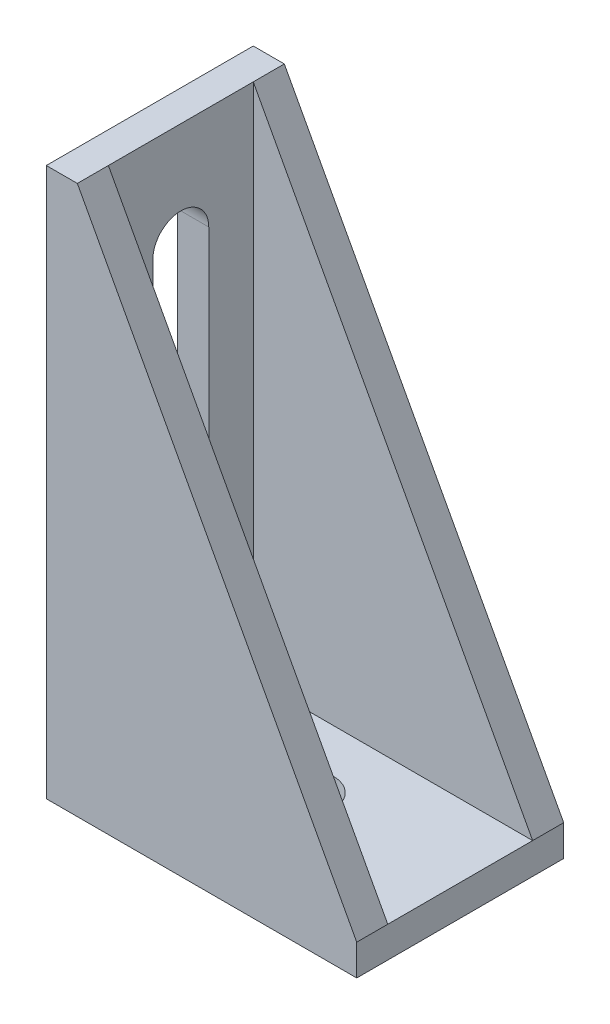
from build123d import *

# Parameters (mm, degrees)
SKETCH1_W           = 30
SKETCH1_H           = 20
SKETCH1_R           = 2.75
BOSS_EXTRUDE1_DEPTH = 3
SKETCH2_W           = 3
SKETCH2_H           = 20
BOSS_EXTRUDE2_DEPTH = 50
RIB1_REACH          = 60.6
SKETCH3_WALL_W      = 176.024973172
SKETCH3_WALL_H      = 3
CUT_EXTRUDE1_DEPTH  = 61.3158354


with BuildPart() as part:
    # Sketch1 → Boss-Extrude1 (new body)
    with BuildSketch(Plane(origin=(0, 0, 0), x_dir=(1, 0, 0), z_dir=(0, 1, 0))):
        Rectangle(SKETCH1_W, SKETCH1_H)
        with Locations(Location((0, 0, 0), (0, 0, 270))):
            Circle(SKETCH1_R, mode=Mode.SUBTRACT)
    extrude(amount=BOSS_EXTRUDE1_DEPTH)

    # Sketch2 → Boss-Extrude2 (add)
    with BuildSketch(Plane(origin=(0, 3, 0), x_dir=(1, 0, 0), z_dir=(0, 1, 0))):
        with Locations((-13.5, 0)):
            Rectangle(SKETCH2_W, SKETCH2_H)
    extrude(amount=BOSS_EXTRUDE2_DEPTH)

    # Sketch3 wall → Rib1 (add, up to next)
    with BuildSketch(Plane(origin=(1.5, 28, 10), x_dir=(0.475148914735, -0.879905397657, 0), z_dir=(0.879905397657, 0.475148914735, 0)), mode=Mode.PRIVATE) as rib1_sk1:
        with Locations((0, 1.5)):
            Rectangle(SKETCH3_WALL_W, SKETCH3_WALL_H)
    rib1_tool1 = extrude(rib1_sk1.sketch, amount=-RIB1_REACH, mode=Mode.PRIVATE) - part.part
    rib1 = rib1_tool1.solids().sort_by_distance((1.5, 28, 10))[0]
    add(rib1)

    # Mirror1: Rib1 across plane
    add(rib1.mirror(Plane.XY))

    # Sketch4 → Cut-Extrude1 (cut, through all)
    with BuildSketch(Plane(origin=(-12, 0, 0), x_dir=(0, 0, -1), z_dir=(1, 0, 0))):
        with BuildLine():
            Line((2.7, 43), (2.7, 8))
            ThreePointArc((2.7, 8), (0, 5.3), (-2.7, 8))
            Line((-2.7, 8), (-2.7, 43))
            ThreePointArc((-2.7, 43), (0, 45.7), (2.7, 43))
        make_face()
    extrude(amount=-CUT_EXTRUDE1_DEPTH, mode=Mode.SUBTRACT)


solid = part.part
